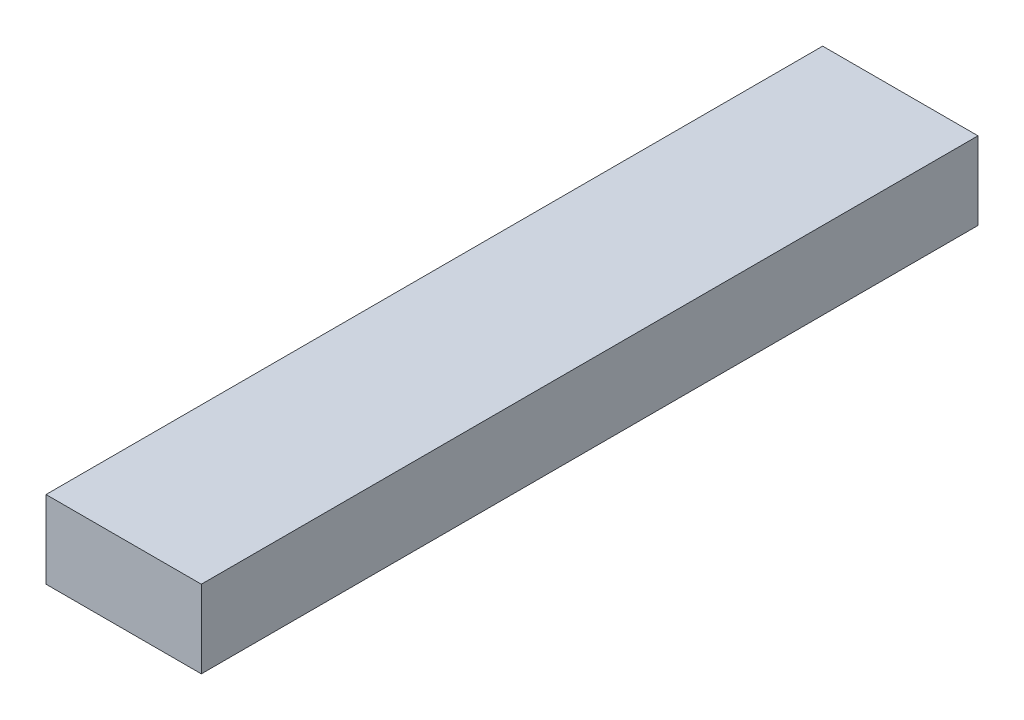
from build123d import *

# Parameters (mm, degrees)
SKETCH_1_W      = 80
SKETCH_1_H      = 40
EXTRUDE_1_DEPTH = 400


with BuildPart() as part:
    # Эскиз1 → Бобышка-Вытянуть1 (new body)
    with BuildSketch(Plane.XY):
        with Locations((16.090225564, 2.631578947)):
            Rectangle(SKETCH_1_W, SKETCH_1_H)
    extrude(amount=EXTRUDE_1_DEPTH)


solid = part.part
